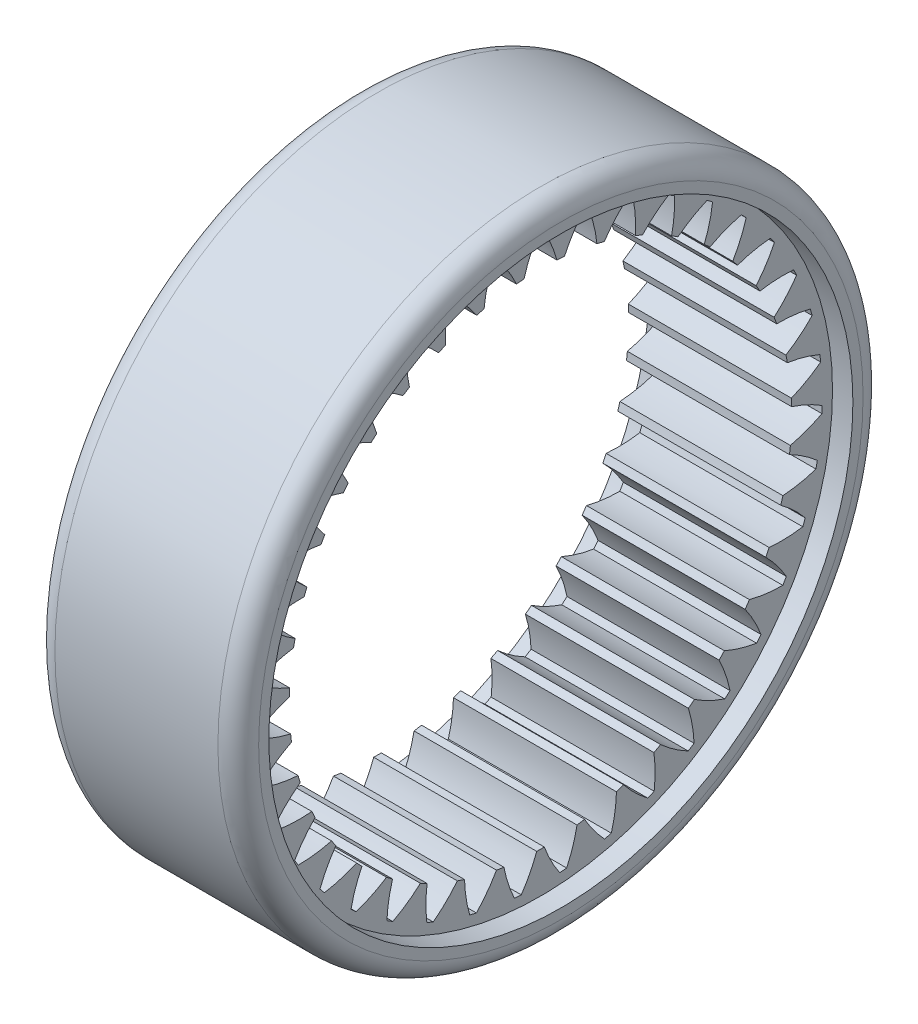
from build123d import *

# Parameters (mm, degrees)
BASPROSKE_W        = 30
BASPROSKE_H        = 10.5
TOOTHCUT_DEPTH     = 74.569694848
TEETHCUTS_COUNT    = 39
TEETHCUTS_ANGLE    = 350.769230769
SKETCH1_R          = 43
CUT_EXTRUDE1_DEPTH = 3
CUT_EXTRUDE2_START = -3
SKETCH2_R          = 43
CUT_EXTRUDE2_DEPTH = 3
FILLET1_R          = 3


with BuildPart() as part:
    # BasProSke → Base-Revolve (revolve)
    with BuildSketch(Plane(origin=(0, 0, 0), x_dir=(1, 0, 0), z_dir=(0, 1, 0))):
        with Locations((15, 42.25)):
            Rectangle(BASPROSKE_W, BASPROSKE_H)
    revolve(axis=Axis((-10, 0, 0), (1, 0, 0)))

    # TooCutSke → ToothCut (cut, through all)
    with BuildSketch(Plane(origin=(0, 0, 0), x_dir=(0, 0, -1), z_dir=(1, 0, 0))):
        with BuildLine():
            ThreePointArc((2.427122234, 36.894852254), (1.617350739, 39.257796068), (0.512163684, 41.497839575))
            ThreePointArc((0.512163684, 41.497839575), (0, 41.501), (-0.512163684, 41.497839575))
            ThreePointArc((-0.512163684, 41.497839575), (-1.617350739, 39.257796068), (-2.427122234, 36.894852254))
            ThreePointArc((-2.427122234, 36.894852254), (0, 36.9746), (2.427122234, 36.894852254))
        make_face()
    toothcut = extrude(amount=TOOTHCUT_DEPTH, mode=Mode.SUBTRACT)

    # TeethCuts: ToothCut ×39 about axis
    teethcuts_axis = Axis((-10, 0, 0), (1, 0, 0))
    for i in range(1, TEETHCUTS_COUNT):
        add(toothcut.rotate(teethcuts_axis, i * TEETHCUTS_ANGLE / (TEETHCUTS_COUNT - 1)), mode=Mode.SUBTRACT)

    # Sketch1 → Cut-Extrude1 (cut)
    with BuildSketch(Plane(origin=(30, 0, 0), x_dir=(0, 0, -1), z_dir=(1, 0, 0))):
        Circle(SKETCH1_R)
    extrude(amount=-CUT_EXTRUDE1_DEPTH, mode=Mode.SUBTRACT)

    # Sketch2 → Cut-Extrude2 (cut)
    with BuildSketch(Plane.ZY.offset(CUT_EXTRUDE2_START)):
        Circle(SKETCH2_R)
    extrude(amount=CUT_EXTRUDE2_DEPTH, mode=Mode.SUBTRACT)

    # Fillet1
    fillet1_edges = [part.edges().sort_by_distance(p)[0] for p in [
        (0, 0, 47.5),
        (30, 0, 47.5),
    ]]
    fillet(fillet1_edges, radius=FILLET1_R)


solid = part.part
